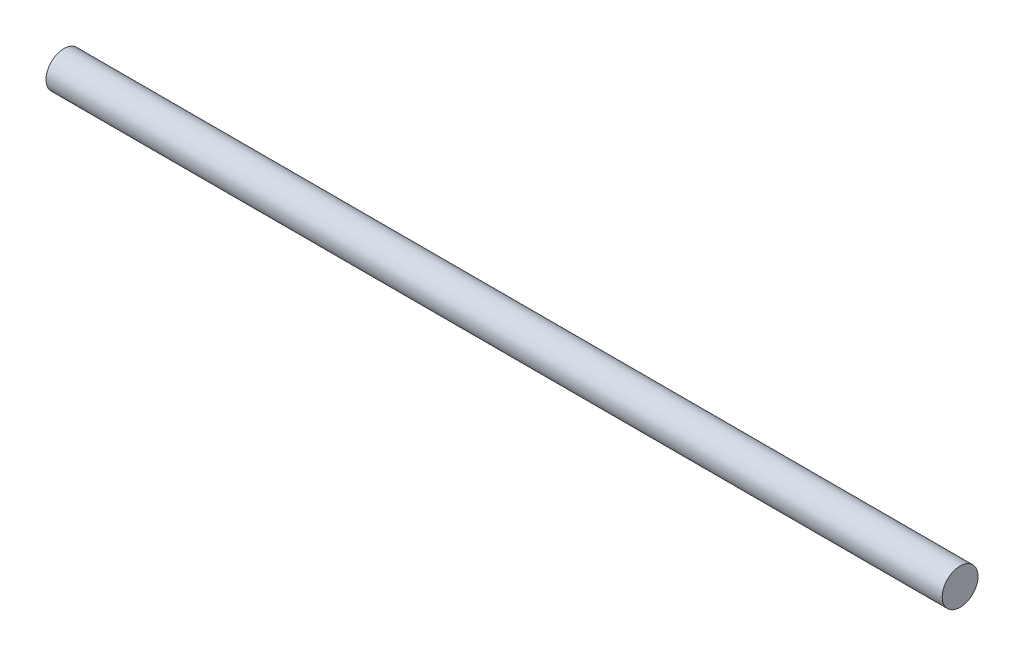
from build123d import *

# Parameters (mm, degrees)
SKETCH_1_W = 200
SKETCH_1_H = 4


with BuildPart() as part:
    # Эскиз1 → Повернуть1 (revolve)
    with BuildSketch(Plane.XY):
        with Locations((0, 2)):
            Rectangle(SKETCH_1_W, SKETCH_1_H)
    revolve(axis=Axis((-100, 0, 0), (1, 0, 0)))


solid = part.part
